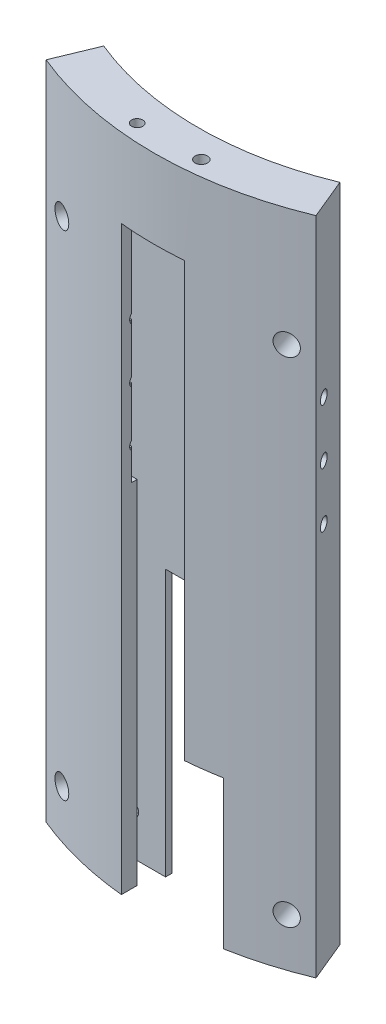
from build123d import *

# Parameters (mm, degrees)
SKETCH1_W                      = 46.2
SKETCH1_H                      = 27.3
BOSS_EXTRUDE1_DEPTH            = 107
CUT_EXTRUDE1_DEPTH             = 24
CUT_EXTRUDE2_DEPTH             = 19.2
CUT_EXTRUDE3_DEPTH             = 50
CUT_EXTRUDE4_DEPTH             = 1
SKETCH6_W                      = 24.8
SKETCH6_H                      = 1.7
CUT_EXTRUDE5_DEPTH             = 5.48
FILLET1_R                      = 3.1
SKETCH7_W                      = 27.3
SKETCH7_H                      = 107
BOSS_EXTRUDE2_DEPTH            = 35.75
SKETCH8_W                      = 27.3
SKETCH8_H                      = 107
BOSS_EXTRUDE3_DEPTH            = 35.75
SKETCH9_W                      = 117.7
SKETCH9_H                      = 107
BOSS_EXTRUDE4_DEPTH            = 39.2125
SKETCH10_OUTSIDE_W             = 154.182
SKETCH10_OUTSIDE_H             = 102.994
CUT_EXTRUDE6_DEPTH             = 107
SKETCH14_R                     = 1
SKETCH15_R                     = 1
SKETCH15_R_2                   = 0.9
CUT_EXTRUDE7_DEPTH             = 50
SKETCH25_R                     = 1.15
CUT_EXTRUDE8_DEPTH             = 4.6
CUT_EXTRUDE8_DIRECTION_2_REACH = 6.619
CUT_EXTRUDE10_START            = -1
SKETCH26_R                     = 1.75
CUT_EXTRUDE10_DEPTH            = 2
SKETCH27_W                     = 5.783250287
SKETCH27_H                     = 3.770726922
CUT_EXTRUDE11_DEPTH            = 45
SKETCH28_W                     = 10.3
SKETCH28_H                     = 4.996145738
CUT_EXTRUDE12_DEPTH            = 100
SKETCH29_W                     = 5.6
SKETCH29_H                     = 4.839207103
CUT_EXTRUDE13_DEPTH            = 30
SKETCH31_R                     = 1.75
CUT_EXTRUDE14_DEPTH            = 21.282725846
CIRPATTERN1_COUNT              = 2
CIRPATTERN1_ANGLE              = 37
LPATTERN1_COUNT                = 2
LPATTERN1_PITCH                = 80
LPATTERN1_COPY_1_SKETCH_R      = 1.75
LPATTERN1_COPY_1_DEPTH         = 21.282725846


with BuildPart() as part:
    # Sketch1 → Boss-Extrude1 (new body)
    with BuildSketch(Plane(origin=(0, 0, 0), x_dir=(1, 0, 0), z_dir=(0, 1, 0))):
        Rectangle(SKETCH1_W, SKETCH1_H)
    extrude(amount=BOSS_EXTRUDE1_DEPTH)

    # Sketch2 → Cut-Extrude1 (cut)
    with BuildSketch(Plane.XZ):
        Polygon((-5.5, 3.65), (4.8, 3.65), (4.8, 3.05), (10.4, 3.05), (10.4, 0.45), (11.7, 0.45), (11.7, -2.15), (13.1, -2.15), (13.1, -3.65), (-4.4, -3.65), (-4.4, -2.25), (-13.1, -2.25), (-13.1, 1.25), (-5.5, 1.25), align=None)
    extrude(amount=-CUT_EXTRUDE1_DEPTH, mode=Mode.SUBTRACT)

    # Sketch3 → Cut-Extrude2 (cut)
    with BuildSketch(Plane.XZ.offset(-24)):
        Polygon((-13.1, 1.25), (-13.1, -2.25), (-4.4, -2.25), (-4.4, -3.65), (13.1, -3.65), (13.1, -2.15), (11.7, -2.15), (11.7, 0.45), (10.4, 0.45), (10.4, 2.15), (4.8, 2.15), (4.8, 3.65), (-5.5, 3.65), (-5.5, 1.25), align=None)
    extrude(amount=-CUT_EXTRUDE2_DEPTH, mode=Mode.SUBTRACT)

    # Sketch4 → Cut-Extrude3 (cut)
    with BuildSketch(Plane.XZ.offset(-43.2)):
        Polygon((-13.1, -2.25), (11.7, -2.25), (11.7, -0.55), (8.9, -0.55), (8.9, 1.15), (4.8, 1.15), (4.8, 3.65), (-5.5, 3.65), (-5.5, 1.25), (-9.3, 1.25), (-9.3, -0.55), (-13.1, -0.55), align=None)
    extrude(amount=-CUT_EXTRUDE3_DEPTH, mode=Mode.SUBTRACT)

    # Sketch5 → Cut-Extrude4 (cut)
    with BuildSketch(Plane.XZ.offset(-93.2)):
        Polygon((-13.1, -2.25), (11.7, -2.25), (11.7, -0.55), (4.8, -0.55), (4.8, 3.65), (-5.5, 3.65), (-5.5, -0.55), (-13.1, -0.55), align=None)
    extrude(amount=-CUT_EXTRUDE4_DEPTH, mode=Mode.SUBTRACT)

    # Sketch6 → Cut-Extrude5 (cut)
    with BuildSketch(Plane.XZ.offset(-94.2)):
        with Locations((-0.7, -1.4)):
            Rectangle(SKETCH6_W, SKETCH6_H)
    extrude(amount=-CUT_EXTRUDE5_DEPTH, mode=Mode.SUBTRACT)

    # Fillet1
    fillet1_edges = [part.edges().sort_by_distance(p)[0] for p in [
        (-13.1, 99.68, -1.4),
        (11.7, 99.68, -1.4),
    ]]
    fillet(fillet1_edges, radius=FILLET1_R)

    # Sketch7 → Boss-Extrude2 (add)
    with BuildSketch(Plane.ZY.offset(23.1)):
        with Locations((0, 53.5)):
            Rectangle(SKETCH7_W, SKETCH7_H)
    extrude(amount=BOSS_EXTRUDE2_DEPTH)

    # Sketch8 → Boss-Extrude3 (add)
    with BuildSketch(Plane(origin=(23.1, 0, 0), x_dir=(0, 0, -1), z_dir=(1, 0, 0))):
        with Locations((0, 53.5)):
            Rectangle(SKETCH8_W, SKETCH8_H)
    extrude(amount=BOSS_EXTRUDE3_DEPTH)

    # Sketch9 → Boss-Extrude4 (add)
    with BuildSketch(Plane(origin=(0, 0, -13.65), x_dir=(-1, 0, 0), z_dir=(0, 0, -1))):
        with Locations((0, 53.5)):
            Rectangle(SKETCH9_W, SKETCH9_H)
    extrude(amount=BOSS_EXTRUDE4_DEPTH)

    # Sketch10 outside → Cut-Extrude6 (cut)
    with BuildSketch(Plane.XZ):
        with Locations((0, -19.606)):
            Rectangle(SKETCH10_OUTSIDE_W, SKETCH10_OUTSIDE_H)
        with BuildLine():
            Line((-19.034171618, -6.868523374), (-21.77035816, -0.262784717))
            ThreePointArc((-21.77035816, -0.262784717), (0.1, 4.0875), (21.97035816, -0.262784717))
            Line((21.97035816, -0.262784717), (19.234171618, -6.868523374))
            ThreePointArc((19.234171618, -6.868523374), (0.1, -3.0625), (-19.034171618, -6.868523374))
        make_face(mode=Mode.SUBTRACT)
    extrude(amount=-CUT_EXTRUDE6_DEPTH, mode=Mode.SUBTRACT)

    # Sketch14 → Cut-Revolve1 (revolve, cut)
    with BuildSketch(Plane(origin=(-18.675071449, 0, -7.735467873), x_dir=(-0.382683432, 0, 0.923879533), z_dir=(-0.923879533, 0, -0.382683432))):
        with Locations((5.750873963, 71.1)):
            Circle(SKETCH14_R)
        with Locations((5.750873963, 62.2)):
            Circle(SKETCH14_R)
        with Locations((5.750873963, 80)):
            Circle(SKETCH14_R)
    revolve(axis=Axis((0.1, 107, -53.0625), (0, -1, 0)), mode=Mode.SUBTRACT)

    # Sketch15 → Cut-Extrude7 (cut)
    with BuildSketch(Plane(origin=(0, 107, 0), x_dir=(1, 0, 0), z_dir=(0, 1, 0))):
        with Locations((4.8, -1.15)):
            Circle(SKETCH15_R)
        with Locations((-5.5, -1.25)):
            Circle(SKETCH15_R_2)
    extrude(amount=-CUT_EXTRUDE7_DEPTH, mode=Mode.SUBTRACT)

    # Sketch25 → Cut-Extrude8 (cut)
    with BuildSketch(Plane.XY.offset(-2.25)):
        with Locations((-9.9075, 95.74)):
            Circle(SKETCH25_R)
        with Locations((8.5075, 95.74)):
            Circle(SKETCH25_R)
        with Locations((-9.9075, 6.84)):
            Circle(SKETCH25_R)
    extrude(amount=CUT_EXTRUDE8_DEPTH, mode=Mode.SUBTRACT)

    # Sketch25 → Cut-Extrude8 direction 2 (cut, up to next)
    with BuildSketch(Plane.XY.offset(-2.25), mode=Mode.PRIVATE) as cut_extrude8_direction_2_sk1:
        with Locations((-9.9075, 95.74)):
            Circle(SKETCH25_R)
    cut_extrude8_direction_2_tool1 = extrude(cut_extrude8_direction_2_sk1.sketch, amount=-CUT_EXTRUDE8_DIRECTION_2_REACH, mode=Mode.PRIVATE) & part.part
    add(cut_extrude8_direction_2_tool1.solids().sort_by_distance((-9.9075, 95.74, -2.25))[0], mode=Mode.SUBTRACT)
    # Sketch25 → Cut-Extrude8 direction 2 (cut, up to next)
    with BuildSketch(Plane.XY.offset(-2.25), mode=Mode.PRIVATE) as cut_extrude8_direction_2_sk2:
        with Locations((8.5075, 95.74)):
            Circle(SKETCH25_R)
    cut_extrude8_direction_2_tool2 = extrude(cut_extrude8_direction_2_sk2.sketch, amount=-CUT_EXTRUDE8_DIRECTION_2_REACH, mode=Mode.PRIVATE) & part.part
    add(cut_extrude8_direction_2_tool2.solids().sort_by_distance((8.5075, 95.74, -2.25))[0], mode=Mode.SUBTRACT)
    # Sketch25 → Cut-Extrude8 direction 2 (cut, up to next)
    with BuildSketch(Plane.XY.offset(-2.25), mode=Mode.PRIVATE) as cut_extrude8_direction_2_sk3:
        with Locations((-9.9075, 6.84)):
            Circle(SKETCH25_R)
    cut_extrude8_direction_2_tool3 = extrude(cut_extrude8_direction_2_sk3.sketch, amount=-CUT_EXTRUDE8_DIRECTION_2_REACH, mode=Mode.PRIVATE) & part.part
    add(cut_extrude8_direction_2_tool3.solids().sort_by_distance((-9.9075, 6.84, -2.25))[0], mode=Mode.SUBTRACT)

    # Sketch26 → Cut-Extrude10 (cut)
    with BuildSketch(Plane.XY.offset(-2.25).offset(CUT_EXTRUDE10_START)):
        with Locations((-9.9075, 95.74)):
            Circle(SKETCH26_R)
        with Locations((8.5075, 95.74)):
            Circle(SKETCH26_R)
        with Locations((-9.9075, 6.84)):
            Circle(SKETCH26_R)
    extrude(amount=-CUT_EXTRUDE10_DEPTH, mode=Mode.SUBTRACT)

    # Sketch27 → Cut-Extrude11 (cut)
    with BuildSketch(Plane.XZ.offset(-43.2)):
        with Locations((10.208374857, -4.549207395)):
            Rectangle(SKETCH27_W, SKETCH27_H)
    extrude(amount=CUT_EXTRUDE11_DEPTH, mode=Mode.SUBTRACT)

    # Sketch28 → Cut-Extrude12 (cut)
    with BuildSketch(Plane.XZ.offset(-94.2)):
        with Locations((-0.35, 3.748072869)):
            Rectangle(SKETCH28_W, SKETCH28_H)
    extrude(amount=CUT_EXTRUDE12_DEPTH, mode=Mode.SUBTRACT)

    # Sketch29 → Cut-Extrude13 (cut)
    with BuildSketch(Plane.XZ.offset(-24)):
        with Locations((7.6, 4.569603552)):
            Rectangle(SKETCH29_W, SKETCH29_H)
    extrude(amount=CUT_EXTRUDE13_DEPTH, mode=Mode.SUBTRACT)

    # Sketch31 → Cut-Extrude14 (cut, through all)
    with BuildSketch(Plane(origin=(-2.156988056, 0, 6.446557768), x_dir=(0, -1, 0), z_dir=(-0.317304656, 0, 0.948323655))):
        with Locations((-7.816936084, -16.453551926)):
            Circle(SKETCH31_R)
    cut_extrude14 = extrude(amount=-CUT_EXTRUDE14_DEPTH, mode=Mode.SUBTRACT)

    # CirPattern1: Cut-Extrude14 ×2 about axis
    cirpattern1_axis = Axis((0.1, 0, -53.0625), (0, 1, 0))
    for i in range(1, CIRPATTERN1_COUNT):
        add(cut_extrude14.rotate(cirpattern1_axis, i * CIRPATTERN1_ANGLE / (CIRPATTERN1_COUNT - 1)), mode=Mode.SUBTRACT)

    # LPattern1: Cut-Extrude14 ×2
    with Locations(*[(0, i * LPATTERN1_PITCH, 0) for i in range(1, LPATTERN1_COUNT)]):
        add(cut_extrude14, mode=Mode.SUBTRACT)

    # LPattern1 copy 1 sketch → LPattern1 copy 1 (cut, through all)
    with BuildSketch(Plane(origin=(34.110934171, 80, -4.178163978), x_dir=(0, -1, 0), z_dir=(0.317304656, 0, 0.948323655))):
        with Locations((-7.816936084, -16.453551926)):
            Circle(LPATTERN1_COPY_1_SKETCH_R)
    extrude(amount=-LPATTERN1_COPY_1_DEPTH, mode=Mode.SUBTRACT)


solid = part.part
